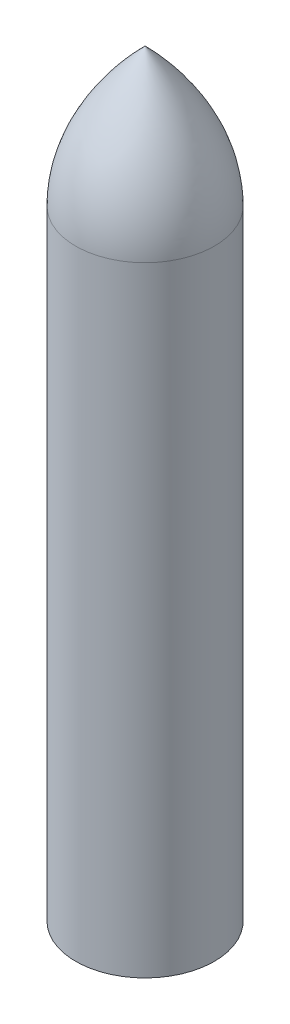
from build123d import *


with BuildPart() as part:
    # Sketch1 → Revolve1 (revolve)
    with BuildSketch(Plane.XY):
        with BuildLine():
            Line((0, 0), (-150, 0))
            Line((-150, 0), (-150, 1340))
            add(Edge.make_bspline(
                [(0, 1640), (-150, 1490), (-150, 1340)],
                knots=[0, 0, 0, 1, 1, 1], degree=2))
            Line((0, 1640), (0, 0))
        make_face()
    revolve(axis=Axis((0, 0, 0), (0, 1, 0)))


solid = part.part
